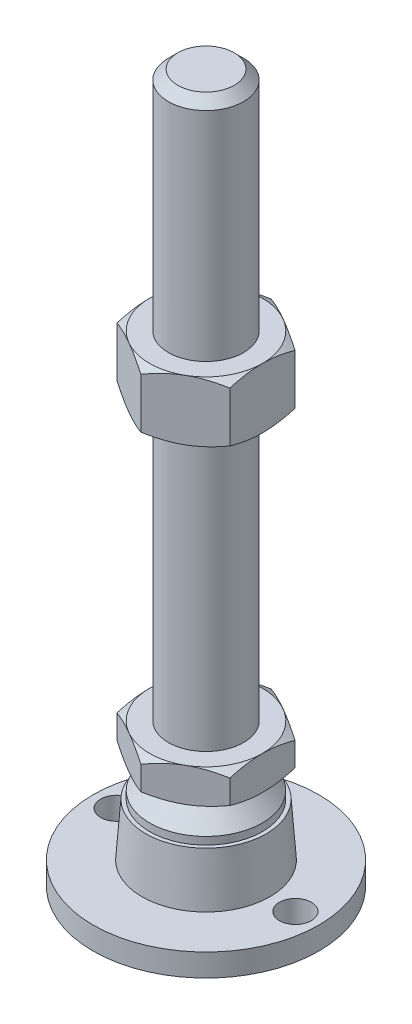
from build123d import *

# Parameters (mm, degrees)
EXTRUDE_1_DEPTH     = 9
EXTRUDE_2_DEPTH     = 16
SKETCH_5_R          = 4.25
CUT_EXTRUDE_1_DEPTH = 7


with BuildPart() as part:
    # Эскиз1 → Повернуть1 (revolve)
    with BuildSketch(Plane.XY, mode=Mode.PRIVATE) as revolve_1_sk:
        Polygon((0, 0), (-30, 0), (-30, 6), (-17, 6), (-16, 20), (-15, 20), (-15, 22), (-10, 27), (-10, 29), (-10, 38), (-10, 185.5), (-7.5, 188), (0, 188), align=None)
    revolve(revolve_1_sk.sketch.rotate(Axis((0, 0, 0), (0, 1, 0)), 180), axis=Axis((0, 0, 0), (0, 1, 0)))  # turned: the seam where the file's is

    # Эскиз2 → Бобышка-Вытянуть1 (add)
    with BuildSketch(Plane(origin=(0, 29, 0), x_dir=(1, 0, 0), z_dir=(0, 1, 0))):
        Polygon((0, 17.320508076), (-15, 8.660254038), (-15, -8.660254038), (0, -17.320508076), (15, -8.660254038), (15, 8.660254038), align=None)
    extrude(amount=EXTRUDE_1_DEPTH)

    # Эскиз3 → Бобышка-Вытянуть2 (add)
    with BuildSketch(Plane(origin=(0, 111.75, 0), x_dir=(1, 0, 0), z_dir=(0, 1, 0))):
        Polygon((15, 8.660254038), (0, 17.320508076), (-15, 8.660254038), (-15, -8.660254038), (0, -17.320508076), (15, -8.660254038), align=None)
    extrude(amount=EXTRUDE_2_DEPTH)

    # Эскиз4 → Вырез-Повернуть2 (revolve, cut)
    with BuildSketch(Plane.XY, mode=Mode.PRIVATE) as cut_revolve_2_sk:
        Polygon((-28.856406461, 127.75), (-15, 127.75), (-28.856406461, 119.75), align=None)
        Polygon((-28.856406461, 111.75), (-28.856406461, 119.75), (-15, 111.75), align=None)
        Polygon((-22.794228634, 38), (-22.794228634, 33.5), (-15, 38), align=None)
        Polygon((-22.794228634, 33.5), (-22.794228634, 29), (-15, 29), align=None)
    revolve(cut_revolve_2_sk.sketch.rotate(Axis((0, 188, 0), (0, -1, 0)), 180), axis=Axis((0, 188, 0), (0, -1, 0)), mode=Mode.SUBTRACT)  # turned: the seam where the file's is

    # Эскиз5 → Вырез-Вытянуть1 (cut, through all)
    with BuildSketch(Plane(origin=(0, 6, 0), x_dir=(1, 0, 0), z_dir=(0, 1, 0))):
        with Locations(Location((-23.75, 0, 0), (0, 0, 180))):  # turned: the seam where the file's is
            Circle(SKETCH_5_R)
        with Locations(Location((23.75, 0, 0), (0, 0, 180))):  # turned: the seam where the file's is
            Circle(SKETCH_5_R)
    extrude(amount=-CUT_EXTRUDE_1_DEPTH, mode=Mode.SUBTRACT)


solid = part.part
